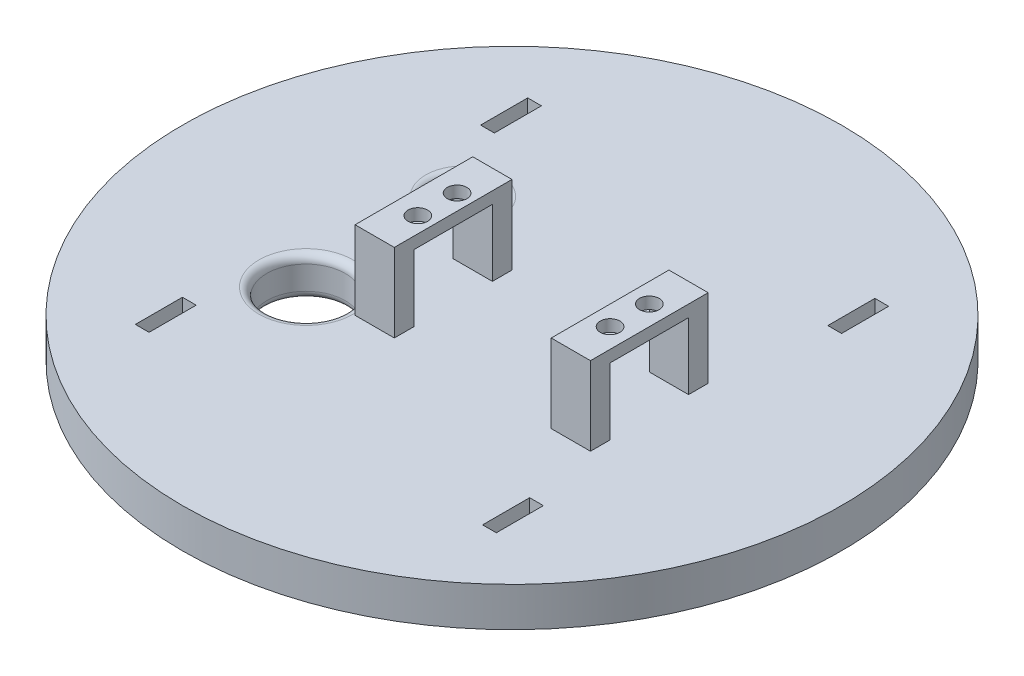
from build123d import *

# Parameters (mm, degrees)
SKETCH1_R               = 84
BASE_DEPTH              = 10
SKETCH3_W               = 10
SKETCH3_H               = 5
MOTOR_MOUNTS_BOTH_DEPTH = 20
SKETCH4_W               = 10
SKETCH4_H               = 20
SKETCH4_R               = 2.5
MOTOR_SCREW_HOLES_DEPTH = 3
SKETCH5_R               = 10.3
GEAR_HOLE_DEPTH         = 5.1
WIRE_HOLES_REACH        = 12
SKETCH6_R               = 7.5
SKETCH6_R_2             = 10
CUT_EXTRUDE1_REACH      = 12
FILLET2_R               = 2


with BuildPart() as part:
    # Sketch1 → base (new body)
    with BuildSketch(Plane(origin=(0, 0, 0), x_dir=(1, 0, 0), z_dir=(0, 1, 0))):
        Circle(SKETCH1_R)
    extrude(amount=BASE_DEPTH)

    # Sketch3 → motor mounts (both) (add)
    with BuildSketch(Plane(origin=(0, 10, 0), x_dir=(1, 0, 0), z_dir=(0, 1, 0))):
        with Locations((-15, 7.5)):
            Rectangle(SKETCH3_W, SKETCH3_H)
        with Locations((-15, -17.5)):
            Rectangle(SKETCH3_W, SKETCH3_H)
        with Locations((35, -17.5)):
            Rectangle(SKETCH3_W, SKETCH3_H)
        with Locations((35, 7.5)):
            Rectangle(SKETCH3_W, SKETCH3_H)
    extrude(amount=MOTOR_MOUNTS_BOTH_DEPTH)

    # Sketch4 → motor screw holes (add)
    with BuildSketch(Plane(origin=(0, 30, 0), x_dir=(1, 0, 0), z_dir=(0, 1, 0))):
        with Locations((-15, -5)):
            Rectangle(SKETCH4_W, SKETCH4_H)
        with Locations((-14, 0)):
            Circle(SKETCH4_R, mode=Mode.SUBTRACT)
        with Locations((-14, -10)):
            Circle(SKETCH4_R, mode=Mode.SUBTRACT)
        with Locations((35, -5)):
            Rectangle(SKETCH4_W, SKETCH4_H)
        with Locations((35, 0)):
            Circle(SKETCH4_R, mode=Mode.SUBTRACT)
        with Locations((35, -10)):
            Circle(SKETCH4_R, mode=Mode.SUBTRACT)
    extrude(amount=-MOTOR_SCREW_HOLES_DEPTH)

    # Sketch5 → gear hole (cut)
    with BuildSketch(Plane.XZ):
        Circle(SKETCH5_R)
    extrude(amount=-GEAR_HOLE_DEPTH, mode=Mode.SUBTRACT)

    # Sketch6 → wire holes (cut, up to next)
    with BuildSketch(Plane(origin=(0, 10, 0), x_dir=(1, 0, 0), z_dir=(0, 1, 0)), mode=Mode.PRIVATE) as wire_holes_sk1:
        with Locations((-32.5, 20)):
            Circle(SKETCH6_R)
    wire_holes_tool1 = extrude(wire_holes_sk1.sketch, amount=-WIRE_HOLES_REACH, mode=Mode.PRIVATE) & part.part
    add(wire_holes_tool1.solids().sort_by_distance((-32.5, 10, -20))[0], mode=Mode.SUBTRACT)
    # Sketch6 → wire holes (cut, up to next)
    with BuildSketch(Plane(origin=(0, 10, 0), x_dir=(1, 0, 0), z_dir=(0, 1, 0)), mode=Mode.PRIVATE) as wire_holes_sk2:
        with Locations((-32.5, -20)):
            Circle(SKETCH6_R_2)
    wire_holes_tool2 = extrude(wire_holes_sk2.sketch, amount=-WIRE_HOLES_REACH, mode=Mode.PRIVATE) & part.part
    add(wire_holes_tool2.solids().sort_by_distance((-32.5, 10, 20))[0], mode=Mode.SUBTRACT)

    # Sketch7 → Cut-Extrude1 (cut, up to next)
    with BuildSketch(Plane(origin=(0, 10, 0), x_dir=(1, 0, 0), z_dir=(0, 1, 0)), mode=Mode.PRIVATE) as cut_extrude1_sk1:
        Polygon((-42.5, 38), (-42.5, 47.5), (-42.5, 50), (-46, 50), (-46, 38), align=None)
    cut_extrude1_tool1 = extrude(cut_extrude1_sk1.sketch, amount=-CUT_EXTRUDE1_REACH, mode=Mode.PRIVATE) & part.part
    add(cut_extrude1_tool1.solids().sort_by_distance((-44.25, 10, -44))[0], mode=Mode.SUBTRACT)
    # Sketch7 → Cut-Extrude1 (cut, up to next)
    with BuildSketch(Plane(origin=(0, 10, 0), x_dir=(1, 0, 0), z_dir=(0, 1, 0)), mode=Mode.PRIVATE) as cut_extrude1_sk2:
        Polygon((42.5, 50), (42.5, 47.5), (42.5, 38), (46, 38), (46, 50), align=None)
    cut_extrude1_tool2 = extrude(cut_extrude1_sk2.sketch, amount=-CUT_EXTRUDE1_REACH, mode=Mode.PRIVATE) & part.part
    add(cut_extrude1_tool2.solids().sort_by_distance((44.25, 10, -44))[0], mode=Mode.SUBTRACT)
    # Sketch7 → Cut-Extrude1 (cut, up to next)
    with BuildSketch(Plane(origin=(0, 10, 0), x_dir=(1, 0, 0), z_dir=(0, 1, 0)), mode=Mode.PRIVATE) as cut_extrude1_sk3:
        Polygon((46, -38), (42.5, -38), (42.5, -47.5), (42.5, -50), (46, -50), align=None)
    cut_extrude1_tool3 = extrude(cut_extrude1_sk3.sketch, amount=-CUT_EXTRUDE1_REACH, mode=Mode.PRIVATE) & part.part
    add(cut_extrude1_tool3.solids().sort_by_distance((44.25, 10, 44))[0], mode=Mode.SUBTRACT)
    # Sketch7 → Cut-Extrude1 (cut, up to next)
    with BuildSketch(Plane(origin=(0, 10, 0), x_dir=(1, 0, 0), z_dir=(0, 1, 0)), mode=Mode.PRIVATE) as cut_extrude1_sk4:
        Polygon((-42.5, -47.5), (-42.5, -38), (-46, -38), (-46, -50), (-42.5, -50), align=None)
    cut_extrude1_tool4 = extrude(cut_extrude1_sk4.sketch, amount=-CUT_EXTRUDE1_REACH, mode=Mode.PRIVATE) & part.part
    add(cut_extrude1_tool4.solids().sort_by_distance((-44.25, 10, 44))[0], mode=Mode.SUBTRACT)

    # Fillet2
    fillet2_edges = [part.edges().sort_by_distance(p)[0] for p in [
        (-40, 10, -20),
        (-40, 0, -20),
        (-42.5, 10, 20),
        (-42.5, 0, 20),
    ]]
    fillet(fillet2_edges, radius=FILLET2_R)


solid = part.part
